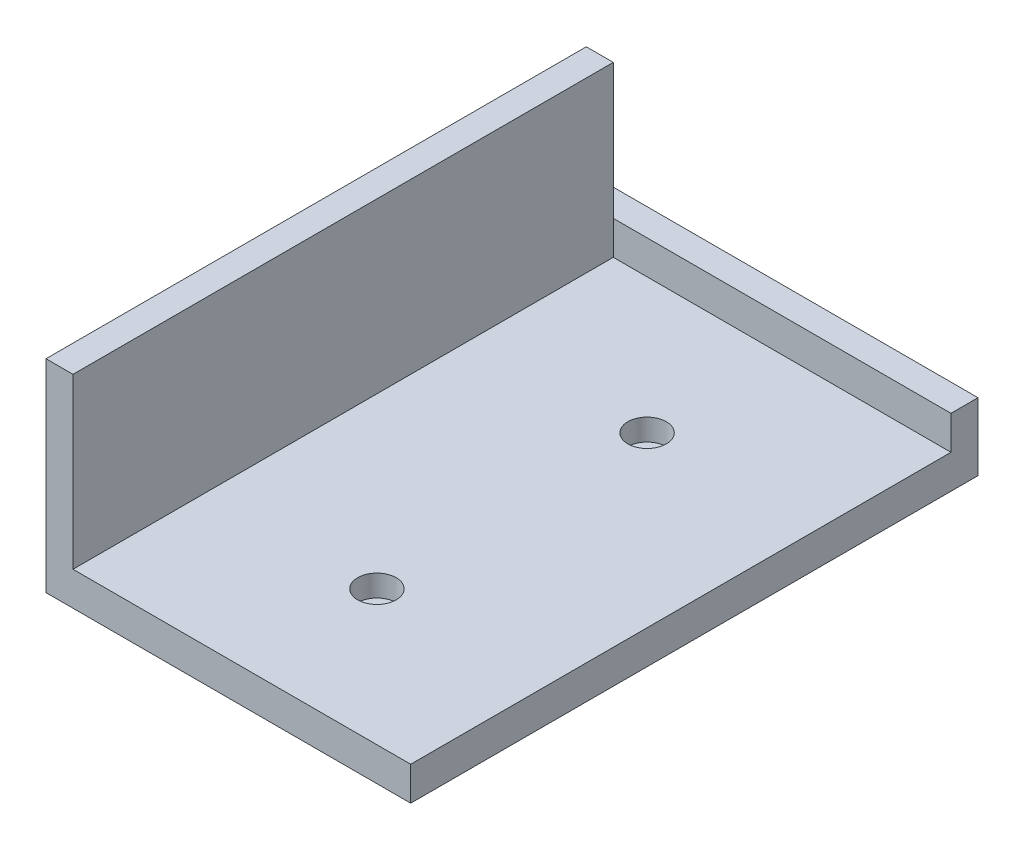
from build123d import *

# Parameters (mm, degrees)
SKETCH1_W                               = 50
SKETCH1_H                               = 80
BOSS_EXTRUDE1_DEPTH                     = 5
BOSS_EXTRUDE2_DEPTH                     = 10
SKETCH1_4_W                             = 4
SKETCH1_4_H                             = 80
BOSS_EXTRUDE3_DEPTH                     = 30
CBORE_FOR_M5_HEX_HEAD_BOLT1_D           = 3
CBORE_FOR_M5_HEX_HEAD_BOLT1_CBORE_D     = 5.7
CBORE_FOR_M5_HEX_HEAD_BOLT1_CBORE_DEPTH = 3.2


with BuildPart() as part:
    # Sketch1 → Boss-Extrude1 (new body)
    with BuildSketch(Plane(origin=(0, 0, 0), x_dir=(1, 0, 0), z_dir=(0, 1, 0))):
        with Locations((-26.495327103, -4.236760125)):
            Rectangle(SKETCH1_W, SKETCH1_H)
    extrude(amount=BOSS_EXTRUDE1_DEPTH)

    # Sketch1_3 → Boss-Extrude2 (add)
    with BuildSketch(Plane(origin=(0, 0, 0), x_dir=(1, 0, 0), z_dir=(0, 1, 0))):
        Polygon((-55.495327103, 35.763239875), (-51.495327103, 35.763239875), (-1.495327103, 35.763239875), (-1.495327103, 39.763239875), (-55.495327103, 39.763239875), align=None)
    extrude(amount=BOSS_EXTRUDE2_DEPTH)

    # Sketch1_4 → Boss-Extrude3 (add)
    with BuildSketch(Plane(origin=(0, 0, 0), x_dir=(1, 0, 0), z_dir=(0, 1, 0))):
        with Locations((-53.495327103, -4.236760125)):
            Rectangle(SKETCH1_4_W, SKETCH1_4_H)
    extrude(amount=BOSS_EXTRUDE3_DEPTH)

    # CBORE for M5 Hex Head Bolt1 (through all)
    with Locations(Plane(origin=(-25.6653615, 5, -85), x_dir=(1, 0, 0), z_dir=(0, 1, 0))):
        with Locations((-0.829965603, -69.236760125), (-0.829965603, -109.236760125)):
            CounterBoreHole(CBORE_FOR_M5_HEX_HEAD_BOLT1_D / 2, CBORE_FOR_M5_HEX_HEAD_BOLT1_CBORE_D / 2, CBORE_FOR_M5_HEX_HEAD_BOLT1_CBORE_DEPTH)


solid = part.part
